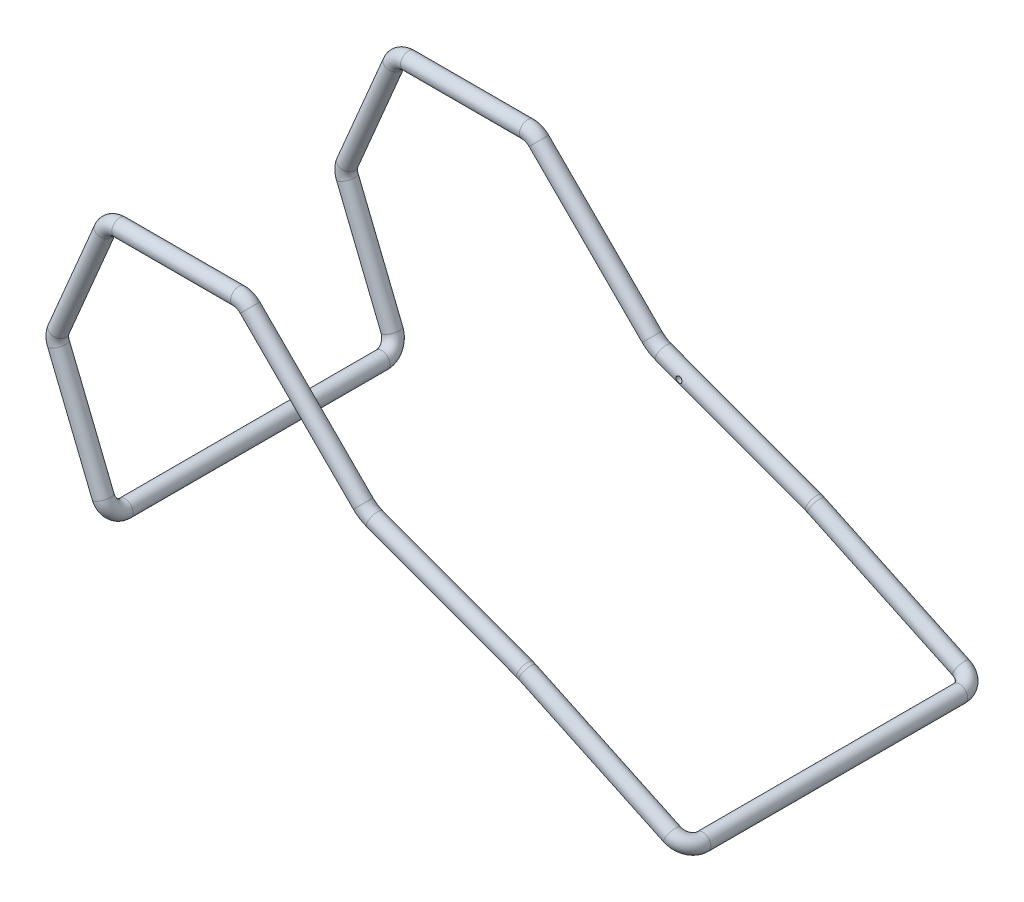
from build123d import *

# Parameters (mm, degrees)
SKETCH4_R = 12.7


with BuildPart() as part:
    # Sweep3: sweep along a curve in space
    with BuildLine() as sweep3_path:
        Line((-9.53033279, 23.544272274, 0), (-80.183119964, 198.088907267, 0))
        ThreePointArc((-80.026125215, 217.528591697, 0), (-82.038019415, 207.82436358, 0), (-80.183119964, 198.088907267, 0))
        Line((-80.026125215, 217.528591697, 0), (-6.563495112, 390.909351641, 0))
        ThreePointArc((-6.563495112, 390.909351641, 0), (2.79769122, 402.176136707, 0), (16.823782413, 406.4, 0))
        Line((16.823782413, 406.4, 0), (205.125789679, 406.4, 0))
        ThreePointArc((205.125789679, 406.4, 0), (214.845948861, 404.466540126, 0), (223.086301921, 398.960512242, 0))
        Line((223.086301921, 398.960512242, 0), (402.191705998, 219.855108165, 0))
        ThreePointArc((402.191705998, 219.855108165, 0), (410.731186113, 212.987220207, 0), (420.544871947, 208.110522966, 0))
        Line((420.544871947, 208.110522966, 0), (658.209816238, 120.515627027, 0))
        ThreePointArc((658.209816238, 120.515627027, 0), (660.272240222, 119.703960701, 0), (662.297296847, 118.803105232, 0))
        Line((662.297296847, 118.803105232, 0), (891.423456056, 10.827669573, 0))
        ThreePointArc((891.423456056, 10.827669573, 0), (907.670326087, 3.171350993, -7.439487758), (914.4, 0, -25.4))
        Line((914.4, 0, -25.4), (914.4, 0, -431.8))
        ThreePointArc((914.4, 0, -431.8), (907.670326087, 3.171350993, -449.760512242), (891.423456056, 10.827669573, -457.2))
        Line((891.423456056, 10.827669573, -457.2), (662.297296847, 118.803105232, -457.2))
        ThreePointArc((662.297296847, 118.803105232, -457.2), (660.272240222, 119.703960701, -457.2), (658.209816238, 120.515627027, -457.2))
        Line((658.209816238, 120.515627027, -457.2), (420.544871947, 208.110522966, -457.2))
        ThreePointArc((402.191705998, 219.855108165, -457.2), (410.731186113, 212.987220207, -457.2), (420.544871947, 208.110522966, -457.2))
        Line((402.191705998, 219.855108165, -457.2), (223.086301921, 398.960512242, -457.2))
        ThreePointArc((223.086301921, 398.960512242, -457.2), (214.845948861, 404.466540126, -457.2), (205.125789679, 406.4, -457.2))
        Line((205.125789679, 406.4, -457.2), (16.823782413, 406.4, -457.2))
        ThreePointArc((16.823782413, 406.4, -457.2), (2.79769122, 402.176136707, -457.2), (-6.563495112, 390.909351641, -457.2))
        Line((-6.563495112, 390.909351641, -457.2), (-80.026125215, 217.528591697, -457.2))
        ThreePointArc((-80.026125215, 217.528591697, -457.2), (-82.038019415, 207.82436358, -457.2), (-80.183119964, 198.088907267, -457.2))
        Line((-80.183119964, 198.088907267, -457.2), (-9.53033279, 23.544272274, -457.2))
        ThreePointArc((-9.53033279, 23.544272274, -457.2), (-2.791369847, 6.895957691, -449.760512242), (0, 0, -431.8))
        Line((0, 0, -431.8), (0, 0, -25.4))
        ThreePointArc((-9.53033279, 23.544272274, 0), (-2.791369847, 6.895957691, -7.439487758), (0, 0, -25.4))
    # Sketch4 → Sweep3 (sweep)
    with BuildSketch(Plane.XY.offset(-25.4)):
        Circle(SKETCH4_R)
    sweep(path=sweep3_path.line)

    # Sketch7 → 3/8 (0.375) Diameter Hole1 (revolve, cut)
    with BuildSketch(Plane(origin=(457.2, 194.600738689, 0), x_dir=(0, -1, 0), z_dir=(1, 0, 0))):
        Polygon((0, 0), (0, 460.061598698), (4.7625, 457.2), (4.7625, 0), align=None)
    revolve(axis=Axis((457.2, 194.600738689, 6.35), (0, 0, -1)), mode=Mode.SUBTRACT)


solid = part.part
